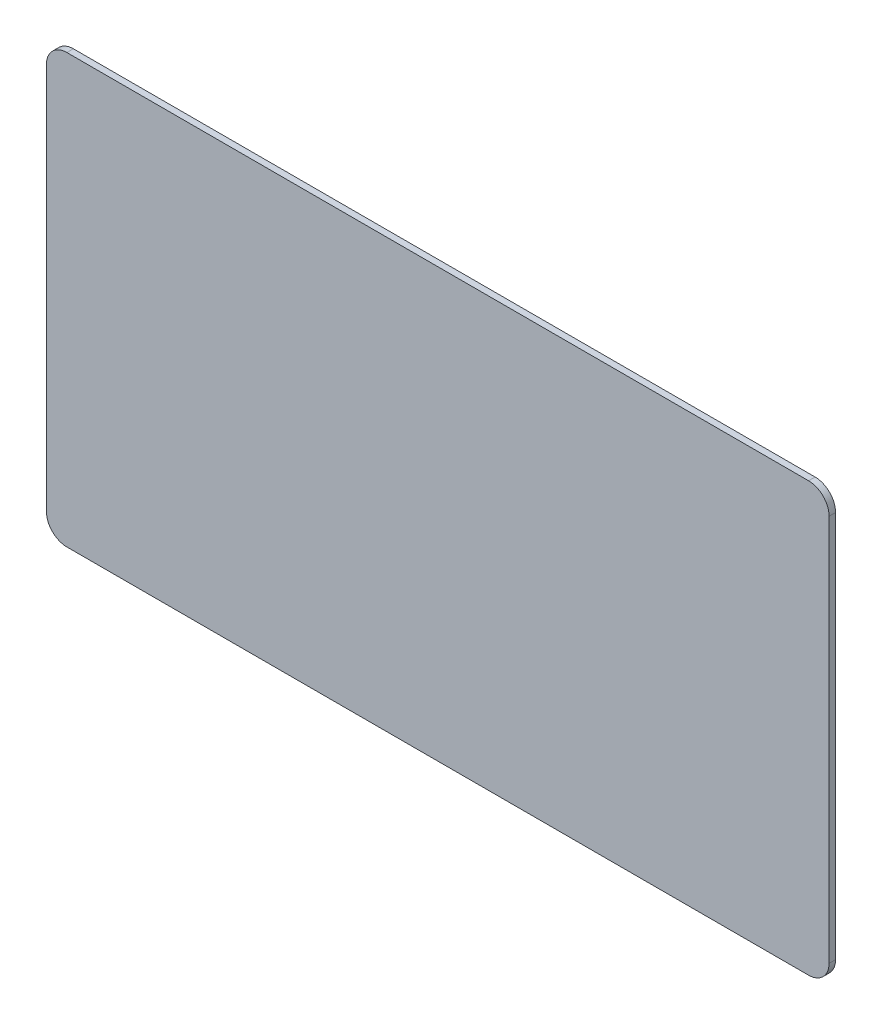
from build123d import *

# Parameters (mm, degrees)
BOSS_EXTRUDE1_DEPTH = 3.175


with BuildPart() as part:
    # Sketch1 → Boss-Extrude1 (new body)
    with BuildSketch(Plane.XY):
        with BuildLine():
            Line((10, 0), (372, 0))
            ThreePointArc((372, 0), (379.071067812, -2.928932188), (382, -10))
            Line((382, -10), (382, -199))
            ThreePointArc((382, -199), (379.071067812, -206.071067812), (372, -209))
            Line((372, -209), (10, -209))
            ThreePointArc((10, -209), (2.928932188, -206.071067812), (0, -199))
            Line((0, -199), (0, -10))
            ThreePointArc((0, -10), (2.928932188, -2.928932188), (10, 0))
        make_face()
    extrude(amount=BOSS_EXTRUDE1_DEPTH)


solid = part.part
